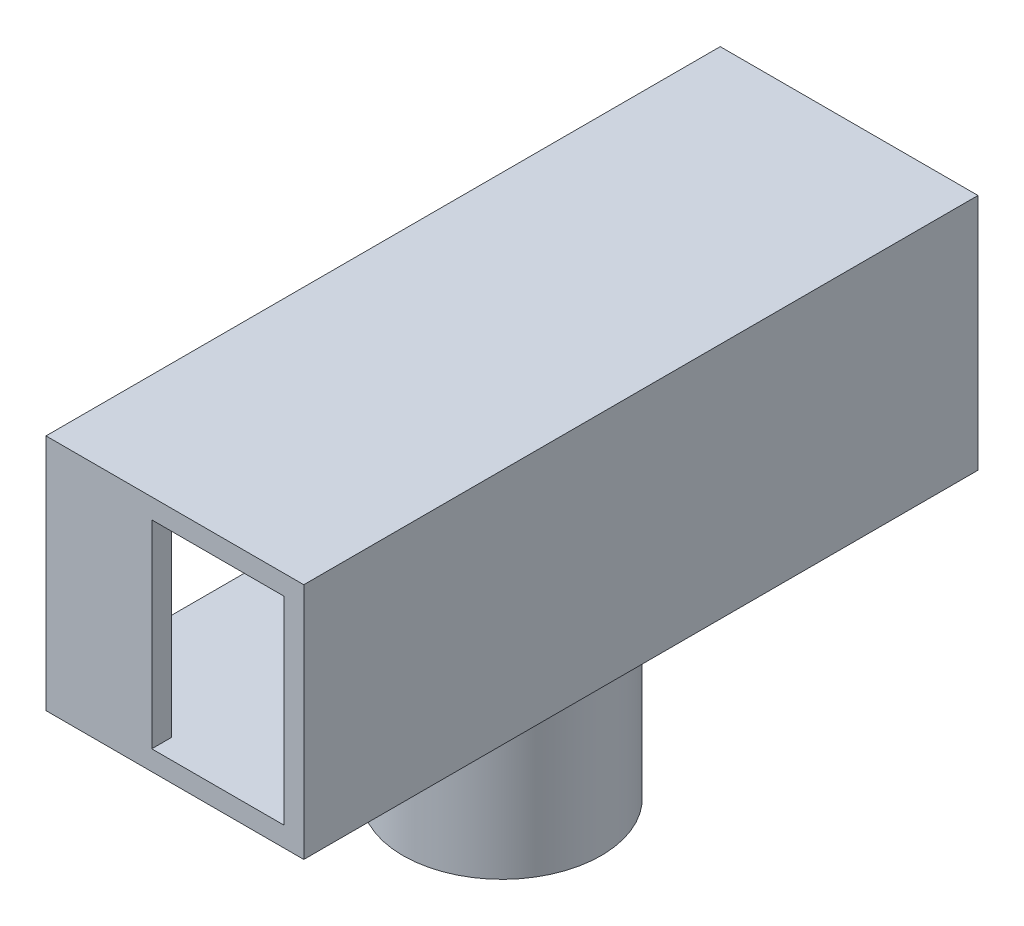
from build123d import *

# Parameters (mm, degrees)
SKETCH_1_R          = 6
EXTRUDE_1_DEPTH     = 1.5
SKETCH_2_R          = 6
EXTRUDE_2_DEPTH     = 14
SKETCH_3_W          = 18
SKETCH_3_H          = 48
EXTRUDE_3_DEPTH     = 15
SHELL_3_T           = 1.5
SKETCH_4_W          = 10
SKETCH_4_H          = 15
CUT_EXTRUDE_1_DEPTH = 15


with BuildPart() as part:
    # 草图1 → 凸台-拉伸1 (new body)
    with BuildSketch(Plane(origin=(0, 0, 0), x_dir=(1, 0, 0), z_dir=(0, 1, 0))):
        with Locations(Location((0, 0, 0), (0, 0, 270))):
            Circle(SKETCH_1_R)
    extrude(amount=EXTRUDE_1_DEPTH)

    # 草图2 → 凸台-拉伸2 (add)
    with BuildSketch(Plane(origin=(0, 1.5, 0), x_dir=(1, 0, 0), z_dir=(0, 1, 0))):
        with Locations(Location((0, 0, 0), (0, 0, 270))):
            Circle(SKETCH_2_R)
    extrude(amount=EXTRUDE_2_DEPTH)

    # 草图3 → 凸台-拉伸3 (add)
    with BuildSketch(Plane(origin=(0, 15.5, 0), x_dir=(1, 0, 0), z_dir=(0, 1, 0))):
        Rectangle(SKETCH_3_W, SKETCH_3_H)
    extrude(amount=EXTRUDE_3_DEPTH)

    # 抽壳3
    shell_3_openings = [part.faces().sort_by_distance(p)[0] for p in [
        (-9, 23, 0),
        (0, 0, 0),
    ]]
    offset(amount=SHELL_3_T, openings=shell_3_openings, kind=Kind.INTERSECTION)

    # 草图4 → 切除-拉伸1 (cut)
    with BuildSketch(Plane(origin=(0, 0, 24), x_dir=(-1, 0, 0), z_dir=(0, 0, -1))):
        with Locations((-4, 23)):
            Rectangle(SKETCH_4_W, SKETCH_4_H)
    extrude(amount=-CUT_EXTRUDE_1_DEPTH, mode=Mode.SUBTRACT)


solid = part.part
